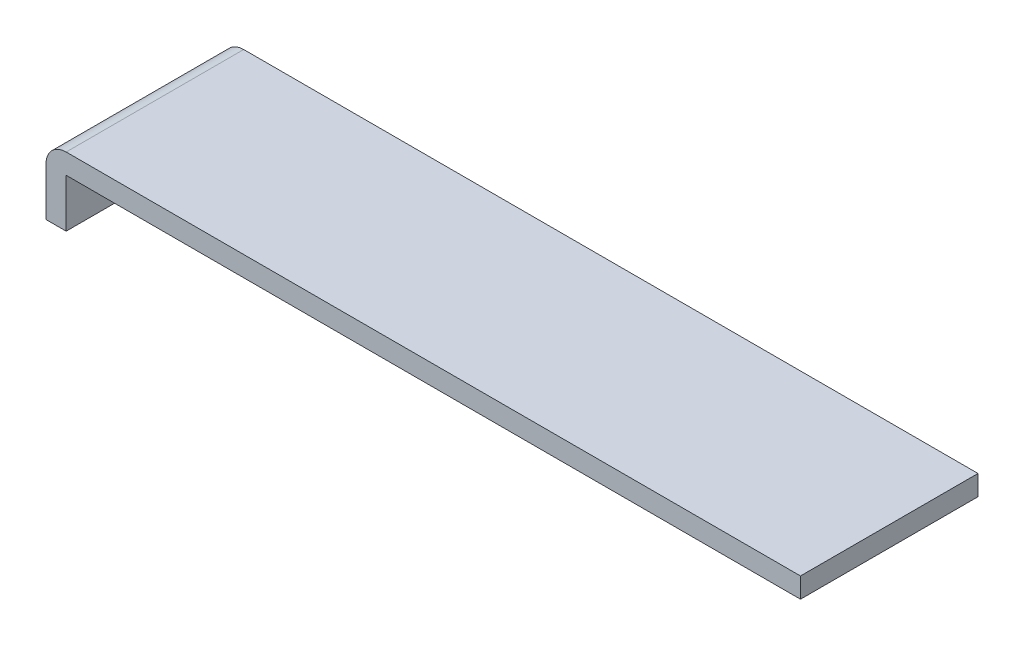
from build123d import *

# Parameters (mm, degrees)
BOSS_EXTRU_1_DEPTH = 4.4
CONG_1_R           = 0.5


with BuildPart() as part:
    # Esquisse1 → Boss.-Extru.1 (new body)
    with BuildSketch(Plane.XY):
        Polygon((0, 0), (0, 1.7), (18.7, 1.7), (18.7, 1.2), (0.5, 1.2), (0.5, 0), align=None)
    extrude(amount=BOSS_EXTRU_1_DEPTH)

    # Congé1
    cong_1_edges = [part.edges().sort_by_distance(p)[0] for p in [
        (0, 1.7, 2.2),
    ]]
    fillet(cong_1_edges, radius=CONG_1_R)


solid = part.part
